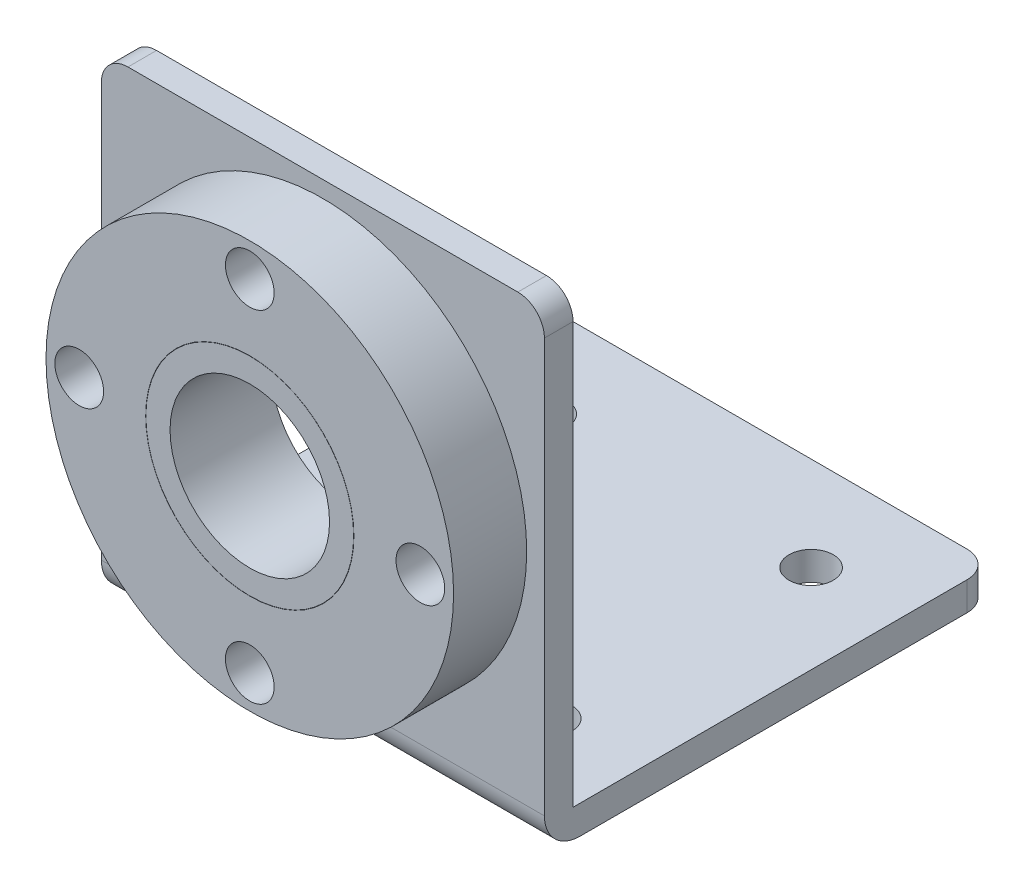
from build123d import *

# Parameters (mm, degrees)
SKETCH1_W               = 50
SKETCH1_H               = 50.7
SKETCH1_R               = 2.5
BOSS_EXTRUDE1_DEPTH     = 3.23
SKETCH2_W               = 50
SKETCH2_H               = 3.23
BOSS_EXTRUDE2_DEPTH     = 50.47
FILLET1_R               = 4
FILLET2_R               = 3
SKETCH4_R               = 2.75
SKETCH4_R_2             = 11.75
CUT_EXTRUDE1_DEPTH      = 1
CUT_EXTRUDE1_DEPTH_BACK = 51.7
SKETCH4_3_R             = 23
SKETCH4_3_R_2           = 2.75
SKETCH4_3_R_3           = 11.75
BOSS_EXTRUDE3_DEPTH     = 8.25
SKETCH5_R               = 11.725
SKETCH5_R_2             = 9
BOSS_EXTRUDE4_DEPTH     = 11.48


with BuildPart() as part:
    # Sketch1 → Boss-Extrude1 (new body)
    with BuildSketch(Plane(origin=(0, 0, 0), x_dir=(1, 0, 0), z_dir=(0, 1, 0))):
        Rectangle(SKETCH1_W, SKETCH1_H)
        with Locations((15, -14.75)):
            Circle(SKETCH1_R, mode=Mode.SUBTRACT)
        with Locations((15, 14.75)):
            Circle(SKETCH1_R, mode=Mode.SUBTRACT)
        with Locations((-15, -14.75)):
            Circle(SKETCH1_R, mode=Mode.SUBTRACT)
        with Locations((-15, 14.75)):
            Circle(SKETCH1_R, mode=Mode.SUBTRACT)
    extrude(amount=BOSS_EXTRUDE1_DEPTH)

    # Sketch2 → Boss-Extrude2 (add)
    with BuildSketch(Plane(origin=(0, 3.23, 0), x_dir=(1, 0, 0), z_dir=(0, 1, 0))):
        with Locations((0, -23.735)):
            Rectangle(SKETCH2_W, SKETCH2_H)
    extrude(amount=BOSS_EXTRUDE2_DEPTH)

    # Fillet1
    fillet1_edges = [part.edges().sort_by_distance(p)[0] for p in [
        (0, 0, 25.35),
    ]]
    fillet(fillet1_edges, radius=FILLET1_R)

    # Fillet2
    fillet2_edges = [part.edges().sort_by_distance(p)[0] for p in [
        (-25, 53.7, 23.735),
        (25, 53.7, 23.735),
        (-25, 1.615, -25.35),
        (25, 1.615, -25.35),
    ]]
    fillet(fillet2_edges, radius=FILLET2_R)

    # Sketch4 → Cut-Extrude1 (cut, two sides)
    with BuildSketch(Plane.XY.offset(25.35)) as cut_extrude1_sk:
        with Locations((-19.25, 28.85)):
            Circle(SKETCH4_R)
        with Locations((19.25, 28.85)):
            Circle(SKETCH4_R)
        with Locations((0, 48.1)):
            Circle(SKETCH4_R)
        with Locations((0, 9.6)):
            Circle(SKETCH4_R)
        with Locations((0, 28.85)):
            Circle(SKETCH4_R_2)
    extrude(amount=CUT_EXTRUDE1_DEPTH, mode=Mode.SUBTRACT)
    extrude(cut_extrude1_sk.sketch, amount=-CUT_EXTRUDE1_DEPTH_BACK, mode=Mode.SUBTRACT)

    # Sketch4_3 → Boss-Extrude3 (add)
    with BuildSketch(Plane.XY.offset(25.35)):
        with Locations((0, 28.85)):
            Circle(SKETCH4_3_R)
        with Locations((0, 48.1)):
            Circle(SKETCH4_3_R_2, mode=Mode.SUBTRACT)
        with Locations((19.25, 28.85)):
            Circle(SKETCH4_3_R_2, mode=Mode.SUBTRACT)
        with Locations((0, 9.6)):
            Circle(SKETCH4_3_R_2, mode=Mode.SUBTRACT)
        with Locations((-19.25, 28.85)):
            Circle(SKETCH4_3_R_2, mode=Mode.SUBTRACT)
        with Locations((0, 28.85)):
            Circle(SKETCH4_3_R_3, mode=Mode.SUBTRACT)
    extrude(amount=BOSS_EXTRUDE3_DEPTH)


with BuildPart() as body_2:
    # Sketch5 → Boss-Extrude4 (new body)
    with BuildSketch(Plane(origin=(0, 0, 22.12), x_dir=(-1, 0, 0), z_dir=(0, 0, -1))):
        with Locations((0, 28.85)):
            Circle(SKETCH5_R)
        with Locations((0, 28.85)):
            Circle(SKETCH5_R_2, mode=Mode.SUBTRACT)
    extrude(amount=-BOSS_EXTRUDE4_DEPTH)


solid = Compound([part.part, body_2.part])
